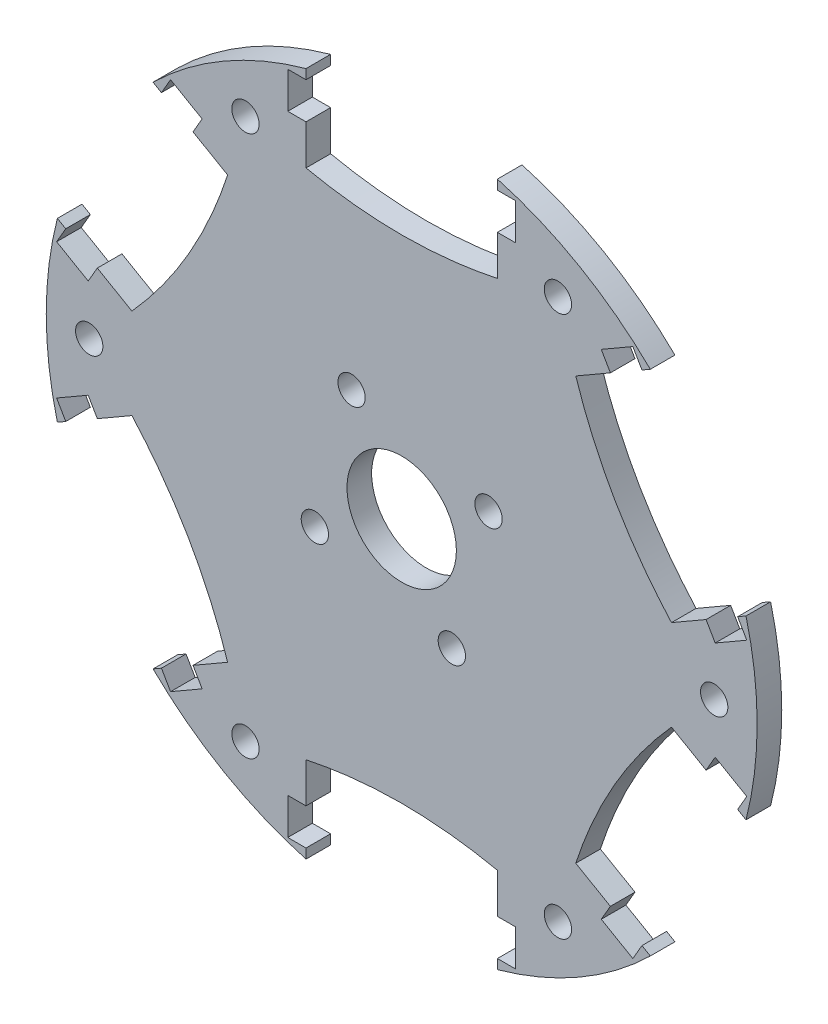
from build123d import *

# Parameters (mm, degrees)
CROQUIS2_R                 = 1.5
CROQUIS2_R_2               = 6
SALIENTE_EXTRUIR2_DEPTH    = 2.7
CROQUIS3_R                 = 1.5
CROQUIS3_W                 = 2
CROQUIS3_H                 = 4
CORTAR_EXTRUIR1_DEPTH      = 1.0000001
CORTAR_EXTRUIR1_DEPTH_BACK = 3.7000001


with BuildPart() as part:
    # Croquis2 → Saliente-Extruir2 (new body)
    with BuildSketch(Plane.XY):
        with BuildLine():
            Line((-10.5, 28.115792599), (-10.5, 37.559952077))
            ThreePointArc((-10.5, 37.559952077), (-19.5, 33.774990748), (-27.277872663, 27.873242778))
            Line((-27.277872663, 27.873242778), (-19.098990638, 23.151163039))
            add(Edge.make_bspline(
                [(-29.598990638, 4.96462956), (-22.416381166, 12.9421037), (-19.098990638, 23.151163039)],
                knots=[0, 0, 0, 1, 1, 1], degree=2))
            Line((-29.598990638, 4.96462956), (-37.777872663, 9.686709299))
            ThreePointArc((-37.777872663, 9.686709299), (-39, 0), (-37.777872663, -9.686709299))
            Line((-37.777872663, -9.686709299), (-29.598990638, -4.96462956))
            add(Edge.make_bspline(
                [(-19.098990638, -23.151163039), (-22.416381166, -12.9421037), (-29.598990638, -4.96462956)],
                knots=[0, 0, 0, 1, 1, 1], degree=2))
            Line((-19.098990638, -23.151163039), (-27.277872663, -27.873242778))
            ThreePointArc((-27.277872663, -27.873242778), (-19.5, -33.774990748), (-10.5, -37.559952077))
            Line((-10.5, -37.559952077), (-10.5, -28.115792599))
            add(Edge.make_bspline(
                [(10.5, -28.115792599), (0, -25.884207401), (-10.5, -28.115792599)],
                knots=[0, 0, 0, 1, 1, 1], degree=2))
            Line((10.5, -28.115792599), (10.5, -37.559952077))
            ThreePointArc((10.5, -37.559952077), (19.5, -33.774990748), (27.277872663, -27.873242778))
            Line((27.277872663, -27.873242778), (19.098990638, -23.151163039))
            add(Edge.make_bspline(
                [(29.598990638, -4.96462956), (22.416381166, -12.9421037), (19.098990638, -23.151163039)],
                knots=[0, 0, 0, 1, 1, 1], degree=2))
            Line((29.598990638, -4.96462956), (37.777872663, -9.686709299))
            ThreePointArc((37.777872663, -9.686709299), (38.693261906, -4.88175), (39, 0))
            ThreePointArc((39, 0), (38.693261906, 4.88175), (37.777872663, 9.686709299))
            Line((37.777872663, 9.686709299), (29.598990638, 4.96462956))
            add(Edge.make_bspline(
                [(19.098990638, 23.151163039), (22.416381166, 12.9421037), (29.598990638, 4.96462956)],
                knots=[0, 0, 0, 1, 1, 1], degree=2))
            Line((19.098990638, 23.151163039), (27.277872663, 27.873242778))
            ThreePointArc((27.277872663, 27.873242778), (19.5, 33.774990748), (10.5, 37.559952077))
            Line((10.5, 37.559952077), (10.5, 28.115792599))
            add(Edge.make_bspline(
                [(-10.5, 28.115792599), (0, 25.884207401), (10.5, 28.115792599)],
                knots=[0, 0, 0, 1, 1, 1], degree=2))
        make_face()
        with Locations((-17.142037335, -29.69087961)):
            Circle(CROQUIS2_R, mode=Mode.SUBTRACT)
        with Locations((-34.28407467, 0)):
            Circle(CROQUIS2_R, mode=Mode.SUBTRACT)
        with Locations((17.142037335, -29.69087961)):
            Circle(CROQUIS2_R, mode=Mode.SUBTRACT)
        with Locations((-17.142037335, 29.69087961)):
            Circle(CROQUIS2_R, mode=Mode.SUBTRACT)
        Circle(CROQUIS2_R_2, mode=Mode.SUBTRACT)
        with Locations((34.28407467, 0)):
            Circle(CROQUIS2_R, mode=Mode.SUBTRACT)
        with Locations((17.142037335, 29.69087961)):
            Circle(CROQUIS2_R, mode=Mode.SUBTRACT)
    extrude(amount=SALIENTE_EXTRUIR2_DEPTH)

    # Croquis3 → Cortar-Extruir1 (cut, two sides)
    with BuildSketch(Plane.XY.offset(2.7)) as cortar_extruir1_sk:
        with Locations((9.526279442, 5.5)):
            Circle(CROQUIS3_R)
        with Locations((5.5, -9.526279442)):
            Circle(CROQUIS3_R)
        with Locations((-9.526279442, -5.5)):
            Circle(CROQUIS3_R)
        with Locations((-5.5, 9.526279442)):
            Circle(CROQUIS3_R)
        with Locations((-11.5, 34.5)):
            Rectangle(CROQUIS3_W, CROQUIS3_H)
        with Locations((11.5, 34.5)):
            Rectangle(CROQUIS3_W, CROQUIS3_H)
        Polygon((22.895825623, 25.34326674), (21.895825623, 27.075317547), (25.359927238, 29.075317547), (26.359927238, 27.34326674), align=None)
        Polygon((36.859927238, 9.15673326), (37.859927238, 7.424682453), (34.395825623, 5.424682453), (33.395825623, 7.15673326), align=None)
        Polygon((33.395825623, -7.15673326), (34.395825623, -5.424682453), (37.859927238, -7.424682453), (36.859927238, -9.15673326), align=None)
        Polygon((26.359927238, -27.34326674), (25.359927238, -29.075317547), (21.895825623, -27.075317547), (22.895825623, -25.34326674), align=None)
        with Locations((11.5, -34.5)):
            Rectangle(CROQUIS3_W, CROQUIS3_H)
        with Locations((-11.5, -34.5)):
            Rectangle(CROQUIS3_W, CROQUIS3_H)
        Polygon((-22.895825623, -25.34326674), (-21.895825623, -27.075317547), (-25.359927238, -29.075317547), (-26.359927238, -27.34326674), align=None)
        Polygon((-36.859927238, -9.15673326), (-37.859927238, -7.424682453), (-34.395825623, -5.424682453), (-33.395825623, -7.15673326), align=None)
        Polygon((-33.395825623, 7.15673326), (-34.395825623, 5.424682453), (-37.859927238, 7.424682453), (-36.859927238, 9.15673326), align=None)
        Polygon((-26.359927238, 27.34326674), (-25.359927238, 29.075317547), (-21.895825623, 27.075317547), (-22.895825623, 25.34326674), align=None)
    extrude(amount=CORTAR_EXTRUIR1_DEPTH, mode=Mode.SUBTRACT)
    extrude(cortar_extruir1_sk.sketch, amount=-CORTAR_EXTRUIR1_DEPTH_BACK, mode=Mode.SUBTRACT)


solid = part.part
